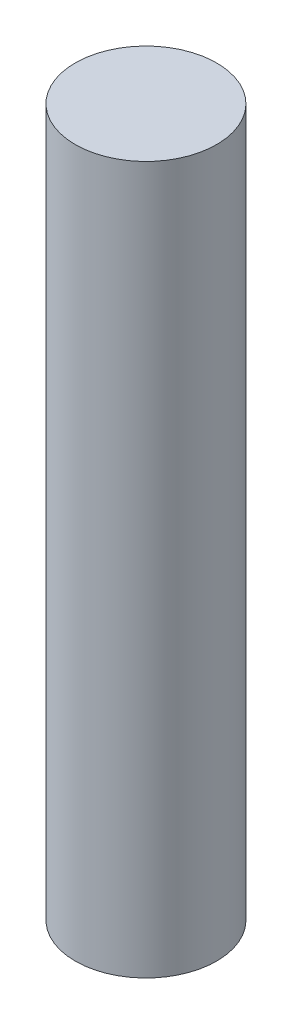
from build123d import *

# Parameters (mm, degrees)
SKETCH1_R           = 3.2
BOSS_EXTRUDE1_DEPTH = 32


with BuildPart() as part:
    # Sketch1 → Boss-Extrude1 (new body)
    with BuildSketch(Plane(origin=(0, 0, 0), x_dir=(1, 0, 0), z_dir=(0, 1, 0))):
        Circle(SKETCH1_R)
    extrude(amount=BOSS_EXTRUDE1_DEPTH)


solid = part.part
